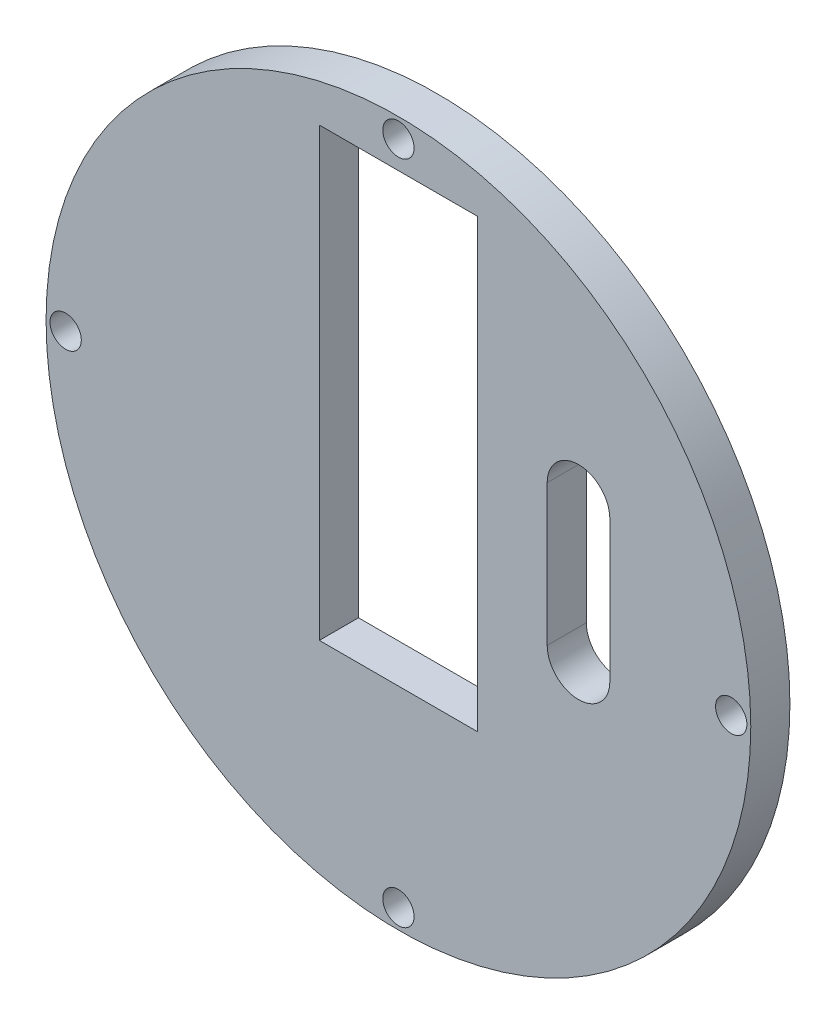
from build123d import *

# Parameters (mm, degrees)
SKETCH1_R           = 45
SKETCH1_R_2         = 2
SKETCH1_W           = 20.2
SKETCH1_H           = 57
BOSS_EXTRUDE1_DEPTH = 5
CUT_EXTRUDE1_DEPTH  = 10


with BuildPart() as part:
    # Sketch1 → Boss-Extrude1 (new body)
    with BuildSketch(Plane.XY):
        Circle(SKETCH1_R)
        with Locations((42.5, 0)):
            Circle(SKETCH1_R_2, mode=Mode.SUBTRACT)
        with Locations((0, -42.5)):
            Circle(SKETCH1_R_2, mode=Mode.SUBTRACT)
        with Locations((-42.5, 0)):
            Circle(SKETCH1_R_2, mode=Mode.SUBTRACT)
        with Locations((0, 42.5)):
            Circle(SKETCH1_R_2, mode=Mode.SUBTRACT)
        with Locations((0, 10.5)):
            Rectangle(SKETCH1_W, SKETCH1_H, mode=Mode.SUBTRACT)
    extrude(amount=BOSS_EXTRUDE1_DEPTH)

    # Sketch2 → Cut-Extrude1 (cut)
    with BuildSketch(Plane(origin=(0, 0, 0), x_dir=(-1, 0, 0), z_dir=(0, 0, -1))):
        with BuildLine():
            Line((-19, 14), (-19, -4))
            ThreePointArc((-19, -4), (-23, -8), (-27, -4))
            Line((-27, -4), (-27, 14))
            ThreePointArc((-27, 14), (-23, 18), (-19, 14))
        make_face()
    extrude(amount=-CUT_EXTRUDE1_DEPTH, mode=Mode.SUBTRACT)


solid = part.part
